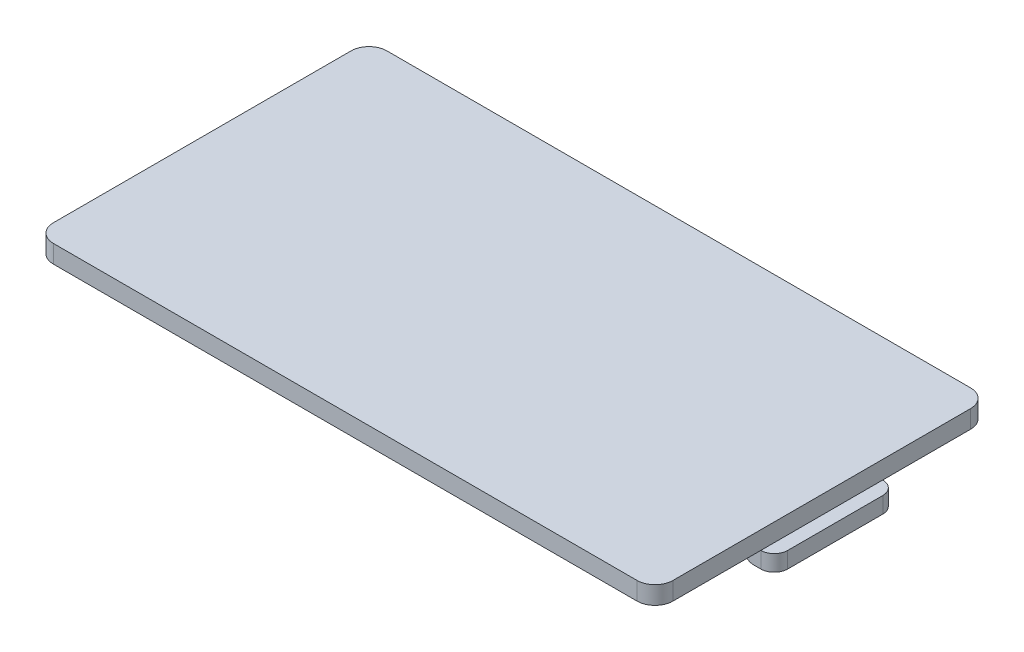
from build123d import *

# Parameters (mm, degrees)
SKETCH_1_W          = 69.1
SKETCH_1_H          = 37.2
EXTRUDE_1_DEPTH     = 2
SKETCH_1_3_W        = 3.5
SKETCH_1_3_H        = 13.6
EXTRUDE_2_DEPTH     = 1.8
SKETCH_1_5_R        = 2.6
CUT_EXTRUDE_1_DEPTH = 1
FILLET_1_R          = 2
FILLET_2_R          = 1.5
FILLET_3_R          = 1.2


with BuildPart() as part:
    # 草图1 → 凸台-拉伸1 (new body)
    with BuildSketch(Plane(origin=(0, 0, 0), x_dir=(1, 0, 0), z_dir=(0, 1, 0))):
        Rectangle(SKETCH_1_W, SKETCH_1_H)
    extrude(amount=EXTRUDE_1_DEPTH)

    # 草图1<3> → 凸台-拉伸2 (add)
    with BuildSketch(Plane(origin=(0, 0, 0), x_dir=(1, 0, 0), z_dir=(0, 1, 0))):
        with Locations((34.3, 0)):
            Rectangle(SKETCH_1_3_W, SKETCH_1_3_H)
    extrude(amount=-EXTRUDE_2_DEPTH)

    # 草图1<5> → 切除-拉伸1 (cut)
    with BuildSketch(Plane(origin=(0, 0, 0), x_dir=(1, 0, 0), z_dir=(0, 1, 0))):
        with Locations((-29.75, 7.1)):
            Circle(SKETCH_1_5_R)
        with Locations((-29.75, -7.1)):
            Circle(SKETCH_1_5_R)
    extrude(amount=CUT_EXTRUDE_1_DEPTH, mode=Mode.SUBTRACT)

    # 圆角1
    fillet_1_edges = [part.edges().sort_by_distance(p)[0] for p in [
        (34.55, 1, 18.6),
        (-34.55, 1, 18.6),
        (-34.55, 1, -18.6),
        (34.55, 1, -18.6),
    ]]
    fillet(fillet_1_edges, radius=FILLET_1_R)

    # 圆角2
    fillet_2_edges = [part.edges().sort_by_distance(p)[0] for p in [
        (36.05, -0.9, -6.8),
        (36.05, -0.9, 6.8),
    ]]
    fillet(fillet_2_edges, radius=FILLET_2_R)

    # 圆角3
    fillet_3_edges = [part.edges().sort_by_distance(p)[0] for p in [
        (32.55, -1.8, 0),
    ]]
    fillet(fillet_3_edges, radius=FILLET_3_R)


solid = part.part
